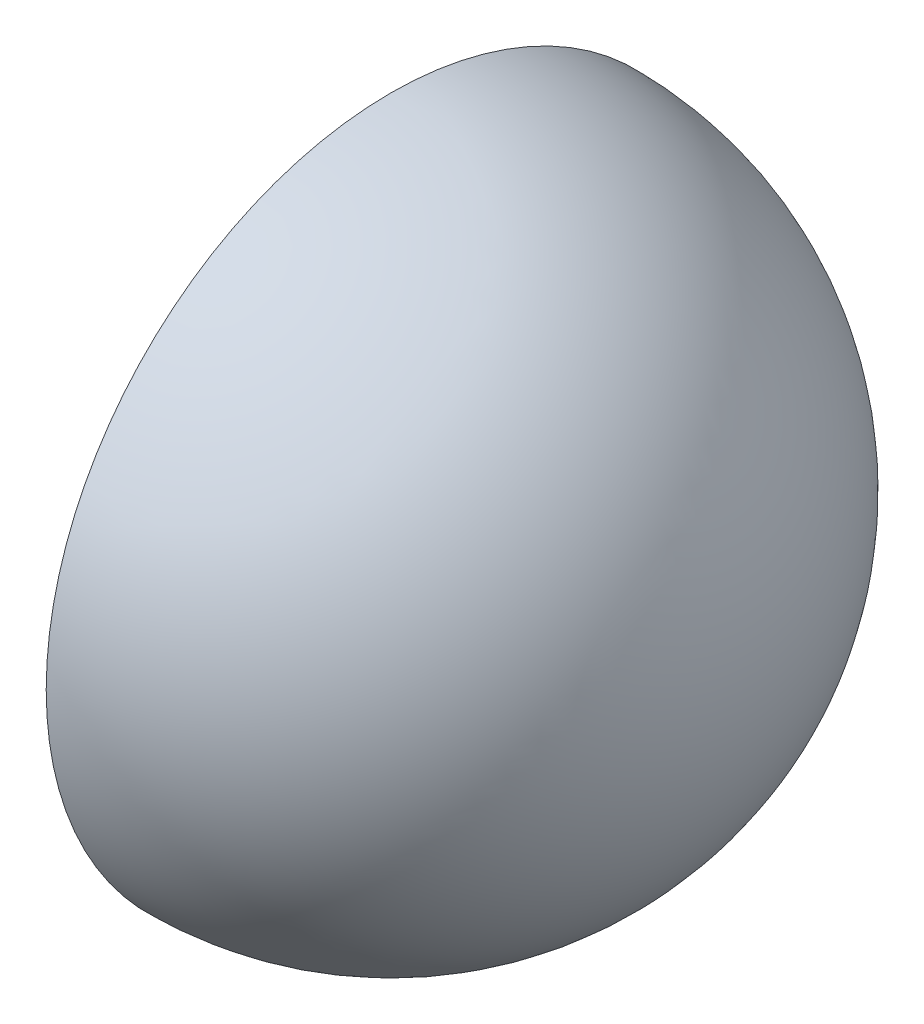
from build123d import *

# Parameters (mm, degrees)
SHELL1_T = -1


with BuildPart() as part:
    # Sketch28 → Revolve1 (revolve)
    with BuildSketch(Plane.XY):
        with BuildLine():
            Line((0, 0), (37.5, 0))
            ThreePointArc((37.5, 0), (26.516504294, -26.516504294), (0, -37.5))
            Line((0, -37.5), (0, 0))
        make_face()
    revolve(axis=Axis((0, 0, 0), (1, 0, 0)))

    # Shell1
    shell1_openings = [part.faces().sort_by_distance(p)[0] for p in [
        (0, 0, 0),
    ]]
    offset(amount=SHELL1_T, openings=shell1_openings, kind=Kind.INTERSECTION)


solid = part.part
